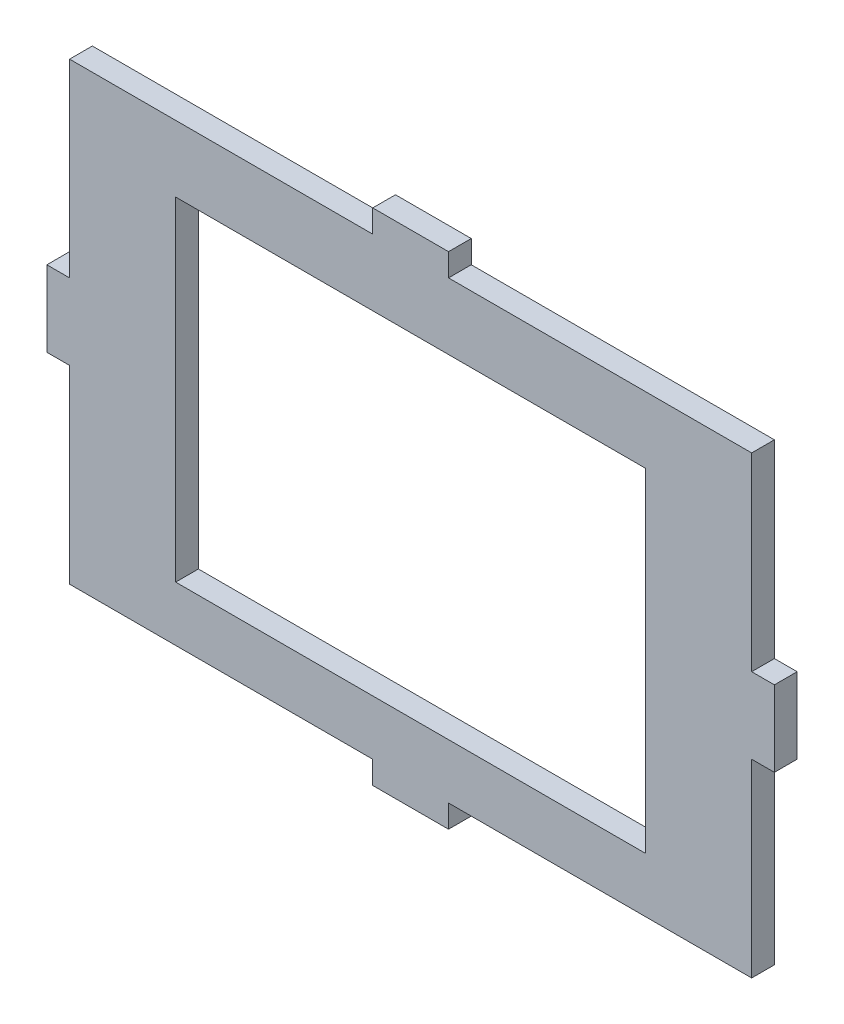
from build123d import *

# Parameters (mm, degrees)
CROQUIS1_W              = 89.98703429
CROQUIS1_H              = 59.995678097
SALIENTE_EXTRUIR1_DEPTH = 3
CROQUIS2_W              = 62
CROQUIS2_H              = 44
CORTAR_EXTRUIR1_DEPTH   = 3
CROQUIS3_W              = 5
CROQUIS3_H              = 3
SALIENTE_EXTRUIR2_DEPTH = 3
CROQUIS4_W              = 5
CROQUIS4_H              = 3
SALIENTE_EXTRUIR3_DEPTH = 3
CROQUIS5_W              = 3
CROQUIS5_H              = 5
SALIENTE_EXTRUIR4_DEPTH = 3
CROQUIS6_W              = 3
CROQUIS6_H              = 5
SALIENTE_EXTRUIR5_DEPTH = 3


with BuildPart() as part:
    # Croquis1 → Saliente-Extruir1 (new body)
    with BuildSketch(Plane.XY):
        with Locations((44.993517145, 0.761655066)):
            Rectangle(CROQUIS1_W, CROQUIS1_H)
    extrude(amount=SALIENTE_EXTRUIR1_DEPTH)

    # Croquis2 → Cortar-Extruir1 (cut)
    with BuildSketch(Plane.XY.offset(3)):
        with Locations((44.993517145, 0)):
            Rectangle(CROQUIS2_W, CROQUIS2_H)
    extrude(amount=-CORTAR_EXTRUIR1_DEPTH, mode=Mode.SUBTRACT)

    # Croquis3 → Saliente-Extruir2 (add)
    with BuildSketch(Plane(origin=(0, 30.759494114, 0), x_dir=(1, 0, 0), z_dir=(0, 1, 0))):
        with Locations((47.493517145, -1.5)):
            Rectangle(CROQUIS3_W, CROQUIS3_H)
        with Locations((42.493517145, -1.5)):
            Rectangle(CROQUIS3_W, CROQUIS3_H)
    extrude(amount=SALIENTE_EXTRUIR2_DEPTH)

    # Croquis4 → Saliente-Extruir3 (add)
    with BuildSketch(Plane.XZ.offset(29.236183983)):
        with Locations((47.493517145, 1.5)):
            Rectangle(CROQUIS4_W, CROQUIS4_H)
        with Locations((42.493517145, 1.5)):
            Rectangle(CROQUIS4_W, CROQUIS4_H)
    extrude(amount=SALIENTE_EXTRUIR3_DEPTH)

    # Croquis5 → Saliente-Extruir4 (add)
    with BuildSketch(Plane(origin=(89.98703429, 0, 0), x_dir=(0, 0, -1), z_dir=(1, 0, 0))):
        with Locations((-1.5, 3.261655066)):
            Rectangle(CROQUIS5_W, CROQUIS5_H)
        with Locations((-1.5, -1.738344934)):
            Rectangle(CROQUIS5_W, CROQUIS5_H)
    extrude(amount=SALIENTE_EXTRUIR4_DEPTH)

    # Croquis6 → Saliente-Extruir5 (add)
    with BuildSketch(Plane.ZY):
        with Locations((1.5, 3.261655066)):
            Rectangle(CROQUIS6_W, CROQUIS6_H)
        with Locations((1.5, -1.738344934)):
            Rectangle(CROQUIS6_W, CROQUIS6_H)
    extrude(amount=SALIENTE_EXTRUIR5_DEPTH)


solid = part.part
